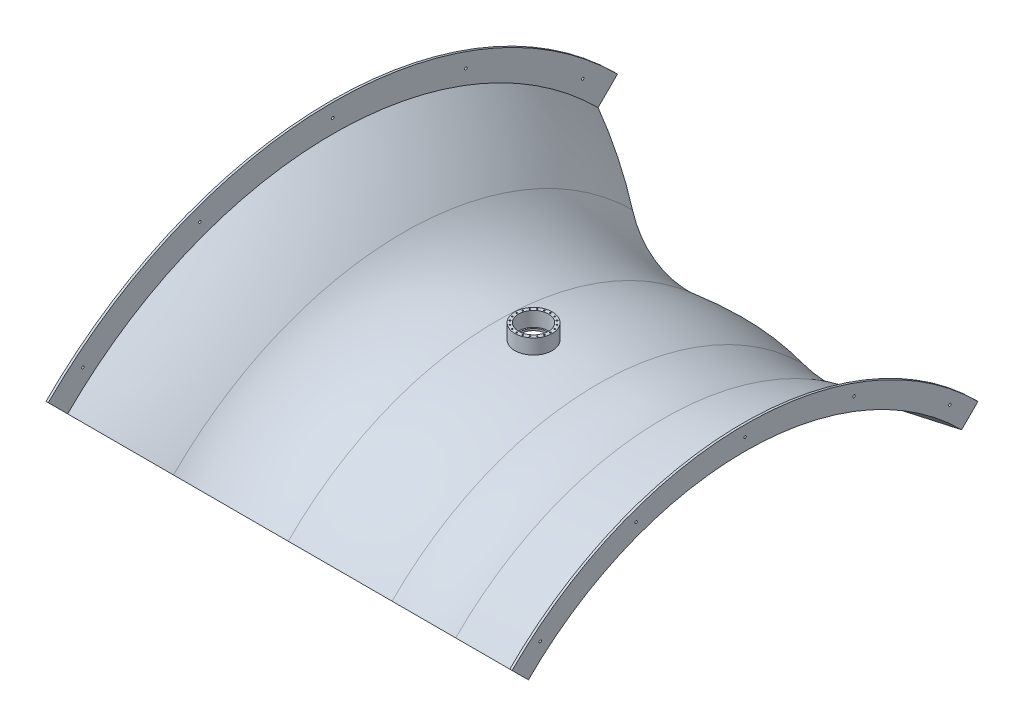
from build123d import *

# Parameters (mm, degrees)
REVOLU_O1_ANGLE                               = 45
REVOLU_O1_OTHER_WAY_ANGLE                     = 45
ESBO_O2_R                                     = 180
CORTE_EXTRUS_O1_DEPTH                         = 5376
RESSALTO_EXTRUS_O1_START                      = 3967.130575
ESBO_O3_R                                     = 250
ESBO_O3_R_2                                   = 200
RESSALTO_EXTRUS_O1_DEPTH                      = 198.869425
BROCA_DE_ROSQUEAR_PARA_TARRAXA_DE_M20X2_D     = 18
BROCA_DE_ROSQUEAR_PARA_TARRAXA_DE_M20X2_DEPTH = 52
BROCA_DE_ROSQUEAR_PARA_TARRAXA_DE_M20X2_TIP   = 5.407745571
ESCALA1_SCALE                                 = 0.2
FURO_COM_FOLGA_DE_M62_D                       = 6.6
FURO_COM_FOLGA_DE_M62_DEPTH                   = 15.999
FURO_COM_FOLGA_DE_M62_TIP                     = 1.982840043
FURO_COM_FOLGA_DE_M63_D                       = 6.6
FURO_COM_FOLGA_DE_M63_DEPTH                   = 15.999
FURO_COM_FOLGA_DE_M63_TIP                     = 1.982840043


with BuildPart() as part:
    # Esboço1 → Revolução1 (revolve)
    with BuildSketch(Plane.XY):
        with BuildLine():
            Line((2824, 4091), (1741, 3900))
            ThreePointArc((1741, 3900), (1298.086339896, 3819.525517366), (849.531150477, 3857.563586562))
            ThreePointArc((849.531150477, 3857.563586562), (185.73337866, 3945.630888977), (-483.40198336, 3920.308983037))
            ThreePointArc((-483.40198336, 3920.308983037), (-1164.206966535, 3981.019603768), (-1760, 4316))
            ThreePointArc((-1760, 4316), (-2217.672127008, 4680.834081254), (-2710, 4997.347822123))
            Line((-2710, 4997.347822123), (-2710, 5375))
            Line((-2710, 5375), (-2680, 5375))
            Line((-2680, 5375), (-2680, 5008.9252282))
            ThreePointArc((-2680, 5008.9252282), (-2194.871885791, 4695.23575344), (-1743.443679293, 4334.732011228))
            ThreePointArc((-1743.443679293, 4334.732011228), (-1156.805425076, 4004.898824526), (-486.461489584, 3945.121065209))
            ThreePointArc((-486.461489584, 3945.121065209), (186.908906373, 3970.603236376), (854.907929911, 3881.978545971))
            ThreePointArc((854.907929911, 3881.978545971), (1297.753157153, 3844.538184437), (1734.958471166, 3924.320321302))
            Line((1734.958471166, 3924.320321302), (2794, 4111.094958427))
            Line((2794, 4111.094958427), (2794, 4400))
            Line((2794, 4400), (2824, 4400))
            Line((2824, 4400), (2824, 4115.620046549))
            Line((2824, 4115.620046549), (2824, 4091))
        make_face()
    revolve(axis=Axis((0, 0, 0), (1, 0, 0)), revolution_arc=REVOLU_O1_ANGLE)

    # Esboço1 → Revolução1 other way (revolve)
    with BuildSketch(Plane.XY):
        with BuildLine():
            Line((2824, 4091), (1741, 3900))
            ThreePointArc((1741, 3900), (1298.086339896, 3819.525517366), (849.531150477, 3857.563586562))
            ThreePointArc((849.531150477, 3857.563586562), (185.73337866, 3945.630888977), (-483.40198336, 3920.308983037))
            ThreePointArc((-483.40198336, 3920.308983037), (-1164.206966535, 3981.019603768), (-1760, 4316))
            ThreePointArc((-1760, 4316), (-2217.672127008, 4680.834081254), (-2710, 4997.347822123))
            Line((-2710, 4997.347822123), (-2710, 5375))
            Line((-2710, 5375), (-2680, 5375))
            Line((-2680, 5375), (-2680, 5008.9252282))
            ThreePointArc((-2680, 5008.9252282), (-2194.871885791, 4695.23575344), (-1743.443679293, 4334.732011228))
            ThreePointArc((-1743.443679293, 4334.732011228), (-1156.805425076, 4004.898824526), (-486.461489584, 3945.121065209))
            ThreePointArc((-486.461489584, 3945.121065209), (186.908906373, 3970.603236376), (854.907929911, 3881.978545971))
            ThreePointArc((854.907929911, 3881.978545971), (1297.753157153, 3844.538184437), (1734.958471166, 3924.320321302))
            Line((1734.958471166, 3924.320321302), (2794, 4111.094958427))
            Line((2794, 4111.094958427), (2794, 4400))
            Line((2794, 4400), (2824, 4400))
            Line((2824, 4400), (2824, 4115.620046549))
            Line((2824, 4115.620046549), (2824, 4091))
        make_face()
    revolve(axis=Axis((0, 0, 0), (-1, 0, 0)), revolution_arc=REVOLU_O1_OTHER_WAY_ANGLE)

    # Esboço2 → Corte-extrusão1 (cut, through all)
    with BuildSketch(Plane(origin=(0, 0, 0), x_dir=(1, 0, 0), z_dir=(0, 1, 0))):
        Circle(ESBO_O2_R)
    extrude(amount=CORTE_EXTRUS_O1_DEPTH, mode=Mode.SUBTRACT)

    # Esboço3 → Ressalto-extrusão1 (add)
    with BuildSketch(Plane(origin=(0, 0, 0), x_dir=(1, 0, 0), z_dir=(0, 1, 0)).offset(RESSALTO_EXTRUS_O1_START)):
        Circle(ESBO_O3_R)
        Circle(ESBO_O3_R_2, mode=Mode.SUBTRACT)
    extrude(amount=RESSALTO_EXTRUS_O1_DEPTH)

    # Broca de rosquear para tarraxa de M20x2.01
    with Locations(Plane(origin=(0, 4166, 0), x_dir=(1, 0, 0), z_dir=(0, 1, 0))):
        with Locations((0, 225), (69.528823734, 213.987716166), (132.251681766, 182.028823734), (182.028823734, 132.251681766), (213.987716166, 69.528823734), (225, 0), (213.987716166, -69.528823734), (182.028823734, -132.251681766), (132.251681766, -182.028823734), (69.528823734, -213.987716166), (0, -225), (-69.528823734, -213.987716166), (-132.251681766, -182.028823734), (-182.028823734, -132.251681766), (-213.987716166, -69.528823734), (-225, 0), (-213.987716166, 69.528823734), (-182.028823734, 132.251681766), (-132.251681766, 182.028823734), (-69.528823734, 213.987716166), (0, 0)):
            Hole(BROCA_DE_ROSQUEAR_PARA_TARRAXA_DE_M20X2_D / 2, depth=BROCA_DE_ROSQUEAR_PARA_TARRAXA_DE_M20X2_DEPTH)
            with Locations((0, 0, -(BROCA_DE_ROSQUEAR_PARA_TARRAXA_DE_M20X2_DEPTH + BROCA_DE_ROSQUEAR_PARA_TARRAXA_DE_M20X2_TIP / 2))):  # 118° drill point
                Cone(0, BROCA_DE_ROSQUEAR_PARA_TARRAXA_DE_M20X2_D / 2, BROCA_DE_ROSQUEAR_PARA_TARRAXA_DE_M20X2_TIP, mode=Mode.SUBTRACT)


with BuildPart() as part_1:
    # Escala1: scaled about (0, 0, 0)
    add(part.part.scale(ESCALA1_SCALE))

    # Furo com folga de M62
    with Locations(Plane(origin=(-536, 0, 0), x_dir=(0, 0, -1), z_dir=(1, 0, 0))):
        with Locations((0, 1038.39252282), (355.151159483, 975.769791173), (667.46584766, 795.454821883), (-355.151159483, 975.769791173), (-667.46584766, 795.454821883)):
            Hole(FURO_COM_FOLGA_DE_M62_D / 2, depth=FURO_COM_FOLGA_DE_M62_DEPTH)
            with Locations((0, 0, -(FURO_COM_FOLGA_DE_M62_DEPTH + FURO_COM_FOLGA_DE_M62_TIP / 2))):  # 118° drill point
                Cone(0, FURO_COM_FOLGA_DE_M62_D / 2, FURO_COM_FOLGA_DE_M62_TIP, mode=Mode.SUBTRACT)

    # Furo com folga de M63
    with Locations(Plane.ZY.offset(-558.8)):
        with Locations((0, 851.109495843), (291.096591754, 799.781312724), (547.082638414, 651.987699776), (-291.096591754, 799.781312724), (-547.082638414, 651.987699776)):
            Hole(FURO_COM_FOLGA_DE_M63_D / 2, depth=FURO_COM_FOLGA_DE_M63_DEPTH)
            with Locations((0, 0, -(FURO_COM_FOLGA_DE_M63_DEPTH + FURO_COM_FOLGA_DE_M63_TIP / 2))):  # 118° drill point
                Cone(0, FURO_COM_FOLGA_DE_M63_D / 2, FURO_COM_FOLGA_DE_M63_TIP, mode=Mode.SUBTRACT)


solid = part_1.part
